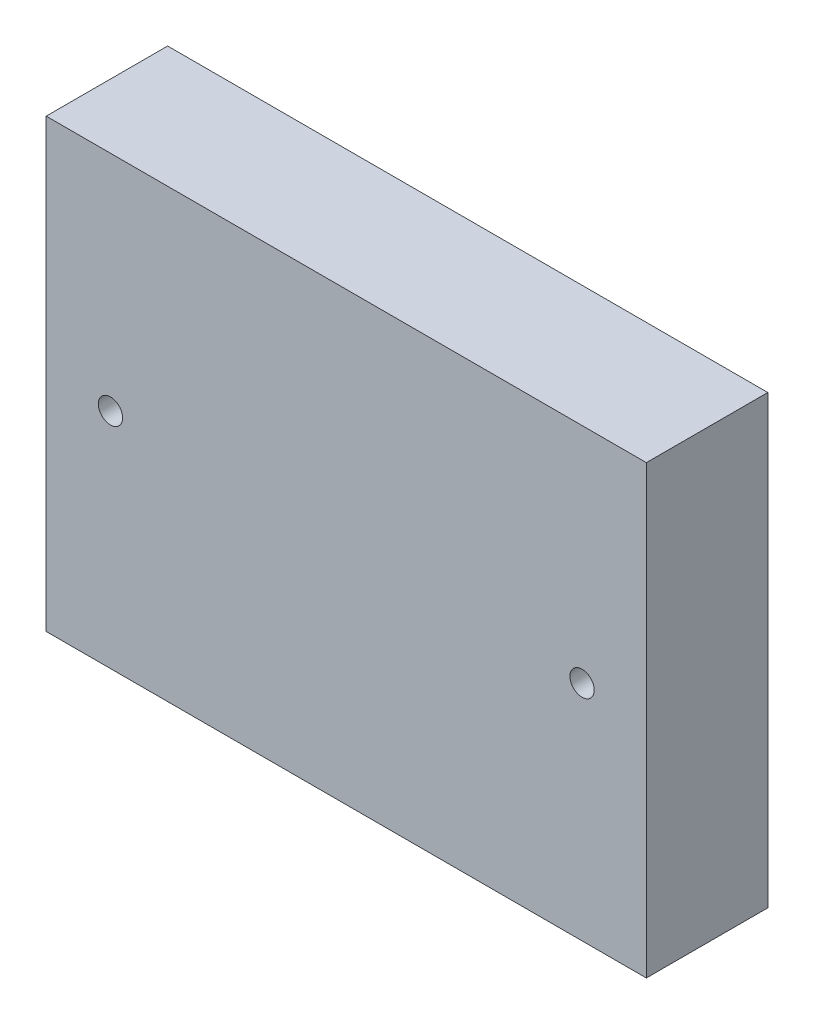
from build123d import *

# Parameters (mm, degrees)
SKETCH1_W           = 47.0662
SKETCH1_H           = 35.0012
BOSS_EXTRUDE1_DEPTH = 9.525
SKETCH2_R           = 0.9525
CUT_EXTRUDE1_DEPTH  = 10.525


with BuildPart() as part:
    # Sketch1 → Boss-Extrude1 (new body)
    with BuildSketch(Plane.XY):
        with Locations((23.5331, 17.5006)):
            Rectangle(SKETCH1_W, SKETCH1_H)
    extrude(amount=BOSS_EXTRUDE1_DEPTH)

    # Sketch2 → Cut-Extrude1 (cut, through all)
    with BuildSketch(Plane(origin=(0, 0, 0), x_dir=(-1, 0, 0), z_dir=(0, 0, -1))):
        with Locations((-5.0419, 17.5006)):
            Circle(SKETCH2_R)
        with Locations((-42.0243, 17.5006)):
            Circle(SKETCH2_R)
    extrude(amount=-CUT_EXTRUDE1_DEPTH, mode=Mode.SUBTRACT)


solid = part.part
